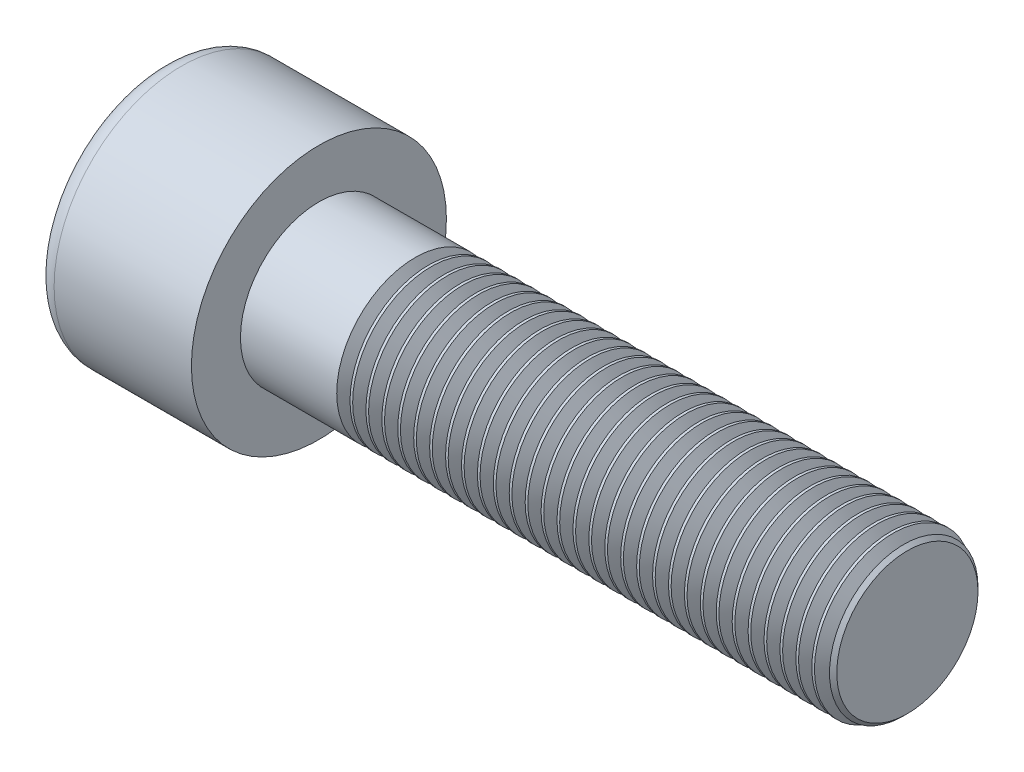
from build123d import *

# Parameters (mm, degrees)
SKETCH1_R           = 6.5
BASEHEAD_DEPTH      = 8
SKETCH2_R           = 4
BASEBODY_DEPTH      = 30
HEXAGONSOCKET_DEPTH = 4
TOPFILLET_R         = 1
CHAMFER1_SIZE       = 0.4
LPATTERN10_COUNT    = 31
LPATTERN10_PITCH    = 0.8118


with BuildPart() as part:
    # Sketch1 → BaseHead (new body)
    with BuildSketch(Plane(origin=(0, 0, 0), x_dir=(0, 0, -1), z_dir=(1, 0, 0))):
        Circle(SKETCH1_R)
    extrude(amount=BASEHEAD_DEPTH)

    # Sketch2 → BaseBody (add)
    with BuildSketch(Plane(origin=(8, 0, 0), x_dir=(0, 0, -1), z_dir=(1, 0, 0))):
        Circle(SKETCH2_R)
    extrude(amount=BASEBODY_DEPTH)

    # Sketch3 → HexagonSocket (cut)
    with BuildSketch(Plane(origin=(0, 0, 0), x_dir=(0, 0, -1), z_dir=(1, 0, 0))):
        Polygon((3.464101615, 0), (1.732050808, 3), (-1.732050808, 3), (-3.464101615, 0), (-1.732050808, -3), (1.732050808, -3), align=None)
    extrude(amount=HEXAGONSOCKET_DEPTH, mode=Mode.SUBTRACT)

    # Sketch4 → Cut-Revolve1 (revolve, cut)
    with BuildSketch(Plane(origin=(-4.19613823, 0.75, 0), x_dir=(-1, 0, 0), z_dir=(0, 0, 1))):
        Polygon((-8.19613823, 3.75), (-9.928189037, 0.75), (-8.19613823, 0.75), align=None)
    revolve(axis=Axis((0.838992387, 0, 0), (-1, 0, 0)), mode=Mode.SUBTRACT)

    # TopFillet
    topfillet_edges = [part.edges().sort_by_distance(p)[0] for p in [
        (0, 0, 6.5),
    ]]
    fillet(topfillet_edges, radius=TOPFILLET_R)

    # Chamfer1
    chamfer1_edges = [part.edges().sort_by_distance(p)[0] for p in [
        (38, 0, 4),
    ]]
    chamfer(chamfer1_edges, length=CHAMFER1_SIZE)

    # Sketch5 → Cut-Revolve10 (revolve, cut)
    with BuildSketch(Plane.XY):
        Polygon((37.6, 3.414133814), (37.93825, 4), (37.93825, 4.6765), (37.26175, 4.6765), (37.26175, 4), align=None)
    cut_revolve10 = revolve(axis=Axis((0, 0, 0), (1, 0, 0)), mode=Mode.SUBTRACT)

    # LPattern10: Cut-Revolve10 ×31
    with Locations(*[(-i * LPATTERN10_PITCH, 0, 0) for i in range(1, LPATTERN10_COUNT)]):
        add(cut_revolve10, mode=Mode.SUBTRACT)


solid = part.part
